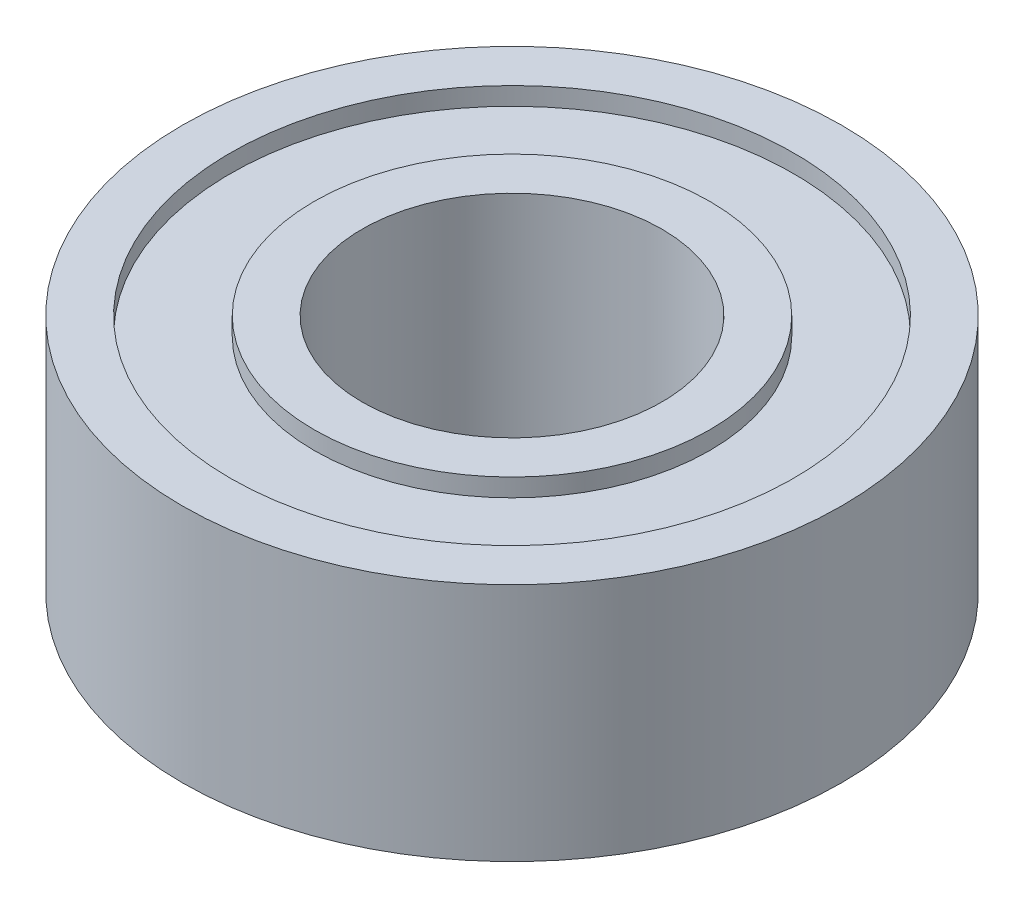
from build123d import *


with BuildPart() as part:
    # Esquisse1 → Révolution1 (revolve)
    with BuildSketch(Plane.XY):
        Polygon((2.5, -2), (2.5, 2), (3.3, 2), (3.3, 1.7), (4.7, 1.7), (4.7, 2), (5.5, 2), (5.5, -2), (4.7, -2), (4.7, -1.7), (3.3, -1.7), (3.3, -2), align=None)
    revolve(axis=Axis((0, 4.534489075, 0), (0, -1, 0)))


solid = part.part
